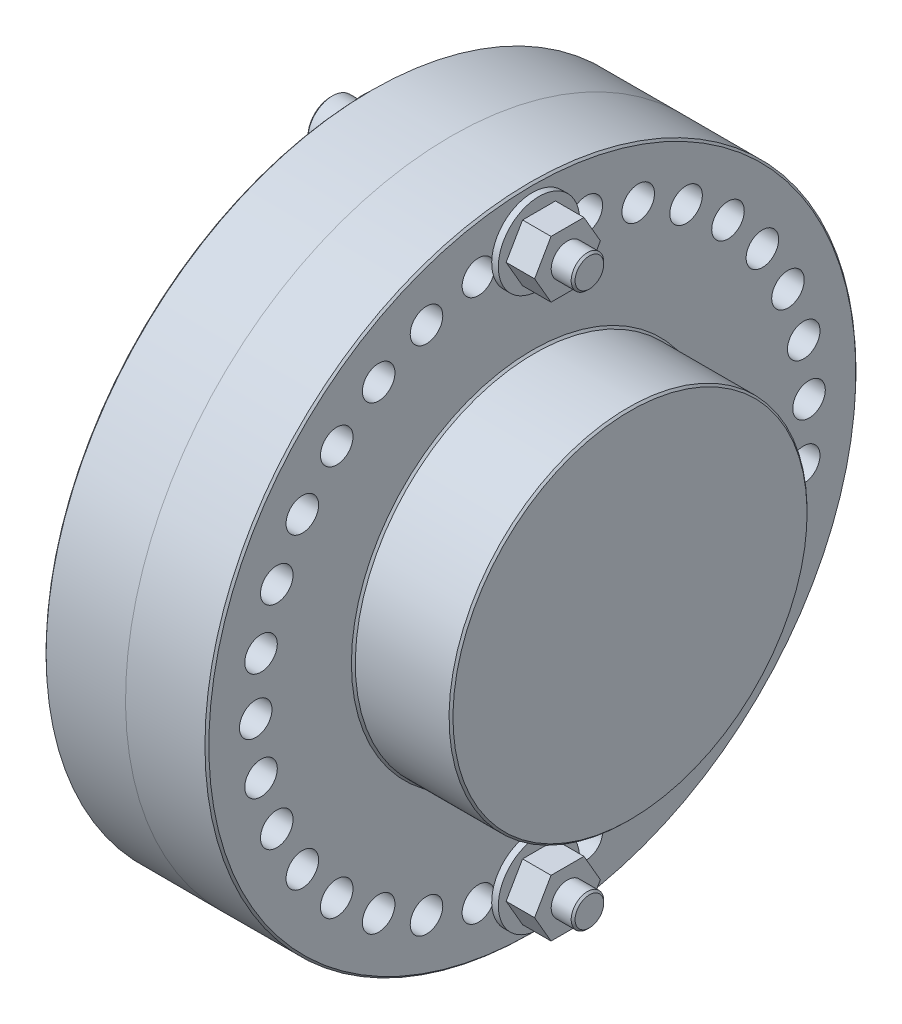
from build123d import *

# Parameters (mm, degrees)
CHAMFER2_SIZE       = 0.381
SKETCH2_R           = 3.175
CUT_EXTRUDE1_DEPTH  = 51.8
SKETCH3_R           = 3.175
CUT_EXTRUDE2_DEPTH  = 51.8
SKETCH4_R           = 7.9375
SKETCH4_R_2         = 3.571875
BOSS_EXTRUDE1_DEPTH = 1.2954
SKETCH5_R           = 4.7625
BOSS_EXTRUDE2_DEPTH = 6.35
CUT_EXTRUDE3_DEPTH  = 4.7625
SKETCH7_R           = 3.175
BOSS_EXTRUDE4_DEPTH = 44.1706
SKETCH8_R           = 3.175
BOSS_EXTRUDE5_DEPTH = 5.55625
CHAMFER1_SIZE       = 0.381


with BuildPart() as part:
    # Sketch1 → Revolve1 (revolve)
    with BuildSketch(Plane.XY):
        Polygon((0, 0), (0, 63.5), (-15.875, 63.5), (-15.875, 34.925), (-34.925, 34.925), (-34.925, 0), align=None)
    revolve(axis=Axis((0, 0, 0), (-1, 0, 0)))

    # Chamfer2
    chamfer2_edges = [part.edges().sort_by_distance(p)[0] for p in [
        (-34.925, -34.925, 0),
        (-15.875, -34.925, 0),
        (-15.875, -63.5, 0),
    ]]
    chamfer(chamfer2_edges, length=CHAMFER2_SIZE)


with BuildPart() as body_2:
    # Mirror1: mirrored copy
    add(part.part.mirror(Plane(origin=(0, 0, 0), x_dir=(0, 0, 1), z_dir=(1, 0, 0))))

    # Sketch3 → Cut-Extrude2 (cut, through all)
    with BuildSketch(Plane(origin=(15.875, 0, 0), x_dir=(0, 0, -1), z_dir=(1, 0, 0))):
        with Locations(Location((0, 53.975, 0), (0, 0, 90))):  # turned: the seam where the file's is
            Circle(SKETCH3_R)
        with Locations(Location((10.530000131, 52.93788551, 0), (0, 0, 90))):  # turned: the seam where the file's is
            Circle(SKETCH3_R)
        with Locations(Location((20.655338262, 49.866397767, 0), (0, 0, 90))):  # turned: the seam where the file's is
            Circle(SKETCH3_R)
        with Locations(Location((29.986903327, 44.878572324, 0), (0, 0, 90))):  # turned: the seam where the file's is
            Circle(SKETCH3_R)
        with Locations(Location((38.166088515, 38.166088515, 0), (0, 0, 90))):  # turned: the seam where the file's is
            Circle(SKETCH3_R)
        with Locations(Location((44.878572324, 29.986903327, 0), (0, 0, 90))):  # turned: the seam where the file's is
            Circle(SKETCH3_R)
        with Locations(Location((49.866397767, 20.655338262, 0), (0, 0, 90))):  # turned: the seam where the file's is
            Circle(SKETCH3_R)
        with Locations(Location((52.93788551, 10.530000131, 0), (0, 0, 90))):  # turned: the seam where the file's is
            Circle(SKETCH3_R)
        with Locations(Location((53.975, 0, 0), (0, 0, 90))):  # turned: the seam where the file's is
            Circle(SKETCH3_R)
        with Locations(Location((52.93788551, -10.530000131, 0), (0, 0, 90))):  # turned: the seam where the file's is
            Circle(SKETCH3_R)
        with Locations(Location((49.866397767, -20.655338262, 0), (0, 0, 90))):  # turned: the seam where the file's is
            Circle(SKETCH3_R)
        with Locations(Location((44.878572324, -29.986903327, 0), (0, 0, 90))):  # turned: the seam where the file's is
            Circle(SKETCH3_R)
        with Locations(Location((38.166088515, -38.166088515, 0), (0, 0, 90))):  # turned: the seam where the file's is
            Circle(SKETCH3_R)
        with Locations(Location((29.986903327, -44.878572324, 0), (0, 0, 90))):  # turned: the seam where the file's is
            Circle(SKETCH3_R)
        with Locations(Location((20.655338262, -49.866397767, 0), (0, 0, 90))):  # turned: the seam where the file's is
            Circle(SKETCH3_R)
        with Locations(Location((10.530000131, -52.93788551, 0), (0, 0, 90))):  # turned: the seam where the file's is
            Circle(SKETCH3_R)
        with Locations(Location((0, -53.975, 0), (0, 0, 90))):  # turned: the seam where the file's is
            Circle(SKETCH3_R)
        with Locations(Location((-10.530000131, -52.93788551, 0), (0, 0, 90))):  # turned: the seam where the file's is
            Circle(SKETCH3_R)
        with Locations(Location((-20.655338262, -49.866397767, 0), (0, 0, 90))):  # turned: the seam where the file's is
            Circle(SKETCH3_R)
        with Locations(Location((-29.986903327, -44.878572324, 0), (0, 0, 90))):  # turned: the seam where the file's is
            Circle(SKETCH3_R)
        with Locations(Location((-38.166088515, -38.166088515, 0), (0, 0, 90))):  # turned: the seam where the file's is
            Circle(SKETCH3_R)
        with Locations(Location((-44.878572324, -29.986903327, 0), (0, 0, 90))):  # turned: the seam where the file's is
            Circle(SKETCH3_R)
        with Locations(Location((-49.866397767, -20.655338262, 0), (0, 0, 90))):  # turned: the seam where the file's is
            Circle(SKETCH3_R)
        with Locations(Location((-52.93788551, -10.530000131, 0), (0, 0, 90))):  # turned: the seam where the file's is
            Circle(SKETCH3_R)
        with Locations(Location((-53.975, 0, 0), (0, 0, 90))):  # turned: the seam where the file's is
            Circle(SKETCH3_R)
        with Locations(Location((-52.93788551, 10.530000131, 0), (0, 0, 90))):  # turned: the seam where the file's is
            Circle(SKETCH3_R)
        with Locations(Location((-49.866397767, 20.655338262, 0), (0, 0, 90))):  # turned: the seam where the file's is
            Circle(SKETCH3_R)
        with Locations(Location((-44.878572324, 29.986903327, 0), (0, 0, 90))):  # turned: the seam where the file's is
            Circle(SKETCH3_R)
        with Locations(Location((-38.166088515, 38.166088515, 0), (0, 0, 90))):  # turned: the seam where the file's is
            Circle(SKETCH3_R)
        with Locations(Location((-29.986903327, 44.878572324, 0), (0, 0, 90))):  # turned: the seam where the file's is
            Circle(SKETCH3_R)
        with Locations(Location((-20.655338262, 49.866397767, 0), (0, 0, 90))):  # turned: the seam where the file's is
            Circle(SKETCH3_R)
        with Locations(Location((-10.530000131, 52.93788551, 0), (0, 0, 90))):  # turned: the seam where the file's is
            Circle(SKETCH3_R)
    extrude(amount=-CUT_EXTRUDE2_DEPTH, mode=Mode.SUBTRACT)


with BuildPart() as part_1:
    add(part.part)

    # Sketch2 → Cut-Extrude1 (cut, through all)
    with BuildSketch(Plane.ZY.offset(15.875)):
        with Locations(Location((0, 53.975, 0), (0, 0, 270))):  # turned: the seam where the file's is
            Circle(SKETCH2_R)
        with Locations(Location((9.917880224, 53.055973055, 0), (0, 0, 270))):  # turned: the seam where the file's is
            Circle(SKETCH2_R)
        with Locations(Location((19.498018932, 50.330188582, 0), (0, 0, 270))):  # turned: the seam where the file's is
            Circle(SKETCH2_R)
        with Locations(Location((28.414175991, 45.890469901, 0), (0, 0, 270))):  # turned: the seam where the file's is
            Circle(SKETCH2_R)
        with Locations(Location((36.362722366, 39.888006307, 0), (0, 0, 270))):  # turned: the seam where the file's is
            Circle(SKETCH2_R)
        with Locations(Location((43.072979842, 32.527204499, 0), (0, 0, 270))):  # turned: the seam where the file's is
            Circle(SKETCH2_R)
        with Locations(Location((48.316438651, 24.058727753, 0), (0, 0, 270))):  # turned: the seam where the file's is
            Circle(SKETCH2_R)
        with Locations(Location((51.91453909, 14.770959889, 0), (0, 0, 270))):  # turned: the seam where the file's is
            Circle(SKETCH2_R)
        with Locations(Location((53.744752166, 4.980184702, 0), (0, 0, 270))):  # turned: the seam where the file's is
            Circle(SKETCH2_R)
        with Locations(Location((53.744752166, -4.980184702, 0), (0, 0, 270))):  # turned: the seam where the file's is
            Circle(SKETCH2_R)
        with Locations(Location((51.91453909, -14.770959889, 0), (0, 0, 270))):  # turned: the seam where the file's is
            Circle(SKETCH2_R)
        with Locations(Location((48.316438651, -24.058727753, 0), (0, 0, 270))):  # turned: the seam where the file's is
            Circle(SKETCH2_R)
        with Locations(Location((43.072979842, -32.527204499, 0), (0, 0, 270))):  # turned: the seam where the file's is
            Circle(SKETCH2_R)
        with Locations(Location((36.362722366, -39.888006307, 0), (0, 0, 270))):  # turned: the seam where the file's is
            Circle(SKETCH2_R)
        with Locations(Location((28.414175991, -45.890469901, 0), (0, 0, 270))):  # turned: the seam where the file's is
            Circle(SKETCH2_R)
        with Locations(Location((19.498018932, -50.330188582, 0), (0, 0, 270))):  # turned: the seam where the file's is
            Circle(SKETCH2_R)
        with Locations(Location((9.917880224, -53.055973055, 0), (0, 0, 270))):  # turned: the seam where the file's is
            Circle(SKETCH2_R)
        with Locations(Location((0, -53.975, 0), (0, 0, 270))):  # turned: the seam where the file's is
            Circle(SKETCH2_R)
        with Locations(Location((-9.917880224, -53.055973055, 0), (0, 0, 270))):  # turned: the seam where the file's is
            Circle(SKETCH2_R)
        with Locations(Location((-19.498018932, -50.330188582, 0), (0, 0, 270))):  # turned: the seam where the file's is
            Circle(SKETCH2_R)
        with Locations(Location((-28.414175991, -45.890469901, 0), (0, 0, 270))):  # turned: the seam where the file's is
            Circle(SKETCH2_R)
        with Locations(Location((-36.362722366, -39.888006307, 0), (0, 0, 270))):  # turned: the seam where the file's is
            Circle(SKETCH2_R)
        with Locations(Location((-43.072979842, -32.527204499, 0), (0, 0, 270))):  # turned: the seam where the file's is
            Circle(SKETCH2_R)
        with Locations(Location((-48.316438651, -24.058727753, 0), (0, 0, 270))):  # turned: the seam where the file's is
            Circle(SKETCH2_R)
        with Locations(Location((-51.91453909, -14.770959889, 0), (0, 0, 270))):  # turned: the seam where the file's is
            Circle(SKETCH2_R)
        with Locations(Location((-53.744752166, -4.980184702, 0), (0, 0, 270))):  # turned: the seam where the file's is
            Circle(SKETCH2_R)
        with Locations(Location((-53.744752166, 4.980184702, 0), (0, 0, 270))):  # turned: the seam where the file's is
            Circle(SKETCH2_R)
        with Locations(Location((-51.91453909, 14.770959889, 0), (0, 0, 270))):  # turned: the seam where the file's is
            Circle(SKETCH2_R)
        with Locations(Location((-48.316438651, 24.058727753, 0), (0, 0, 270))):  # turned: the seam where the file's is
            Circle(SKETCH2_R)
        with Locations(Location((-43.072979842, 32.527204499, 0), (0, 0, 270))):  # turned: the seam where the file's is
            Circle(SKETCH2_R)
        with Locations(Location((-36.362722366, 39.888006307, 0), (0, 0, 270))):  # turned: the seam where the file's is
            Circle(SKETCH2_R)
        with Locations(Location((-28.414175991, 45.890469901, 0), (0, 0, 270))):  # turned: the seam where the file's is
            Circle(SKETCH2_R)
        with Locations(Location((-19.498018932, 50.330188582, 0), (0, 0, 270))):  # turned: the seam where the file's is
            Circle(SKETCH2_R)
        with Locations(Location((-9.917880224, 53.055973055, 0), (0, 0, 270))):  # turned: the seam where the file's is
            Circle(SKETCH2_R)
    extrude(amount=-CUT_EXTRUDE1_DEPTH, mode=Mode.SUBTRACT)


with BuildPart() as body_3:
    # Sketch4 → Boss-Extrude1 (new body)
    with BuildSketch(Plane.ZY.offset(15.875)):
        with Locations(Location((0, 53.975, 0), (0, 0, 270))):  # turned: the seam where the file's is
            Circle(SKETCH4_R)
        with Locations(Location((0, 53.975, 0), (0, 0, 270))):  # turned: the seam where the file's is
            Circle(SKETCH4_R_2, mode=Mode.SUBTRACT)
    extrude(amount=BOSS_EXTRUDE1_DEPTH)


with BuildPart() as body_4:
    # Mirror2: mirrored copy
    add(body_3.part.mirror(Plane(origin=(0, 0, 0), x_dir=(0, 0, 1), z_dir=(1, 0, 0))))


with BuildPart() as body_5:
    # Sketch5 → Boss-Extrude2 (new body)
    with BuildSketch(Plane.ZY.offset(17.1704)):
        with Locations(Location((0, 53.975, 0), (0, 0, 270))):  # turned: the seam where the file's is
            Circle(SKETCH5_R)
    extrude(amount=BOSS_EXTRUDE2_DEPTH)

    # Sketch6 → Cut-Extrude3 (cut)
    with BuildSketch(Plane.ZY.offset(23.5204)):
        Polygon((0, 51.225369343), (2.38125, 52.600184671), (2.38125, 55.349815329), (0, 56.724630657), (-2.38125, 55.349815329), (-2.38125, 52.600184671), align=None)
    extrude(amount=-CUT_EXTRUDE3_DEPTH, mode=Mode.SUBTRACT)

    # Sketch7 → Boss-Extrude4 (add)
    with BuildSketch(Plane(origin=(-17.1704, 0, 0), x_dir=(0, 0, -1), z_dir=(1, 0, 0))):
        with Locations(Location((0, 53.975, 0), (0, 0, 270))):  # turned: the seam where the file's is
            Circle(SKETCH7_R)
    extrude(amount=BOSS_EXTRUDE4_DEPTH)

    # Chamfer1
    chamfer1_edges = [body_5.edges().sort_by_distance(p)[0] for p in [
        (27.0002, 57.15, 0),
        (-23.5204, 58.7375, 0),
    ]]
    chamfer(chamfer1_edges, length=CHAMFER1_SIZE)


with BuildPart() as body_6:
    # Sketch8 → Boss-Extrude5 (new body)
    with BuildSketch(Plane(origin=(17.1704, 0, 0), x_dir=(0, 0, -1), z_dir=(1, 0, 0))):
        Polygon((3.207902433, 59.53125), (-3.207902433, 59.53125), (-6.415804866, 53.975), (-3.207902433, 48.41875), (3.207902433, 48.41875), (6.415804866, 53.975), align=None)
        with Locations(Location((0, 53.975, 0), (0, 0, 90))):  # turned: the seam where the file's is
            Circle(SKETCH8_R, mode=Mode.SUBTRACT)
    extrude(amount=BOSS_EXTRUDE5_DEPTH)


with BuildPart() as body_7:
    # Mirror3: mirrored copy
    add(body_6.part.mirror(Plane.ZX))


with BuildPart() as body_8:
    # Mirror3 2: mirrored copy
    add(body_5.part.mirror(Plane.ZX))


with BuildPart() as body_9:
    # Mirror3 3: mirrored copy
    add(body_4.part.mirror(Plane.ZX))


with BuildPart() as body_10:
    # Mirror3 4: mirrored copy
    add(body_3.part.mirror(Plane.ZX))


solid = Compound([body_2.part, part_1.part, body_3.part, body_4.part, body_5.part, body_6.part, body_7.part, body_8.part, body_9.part, body_10.part])
